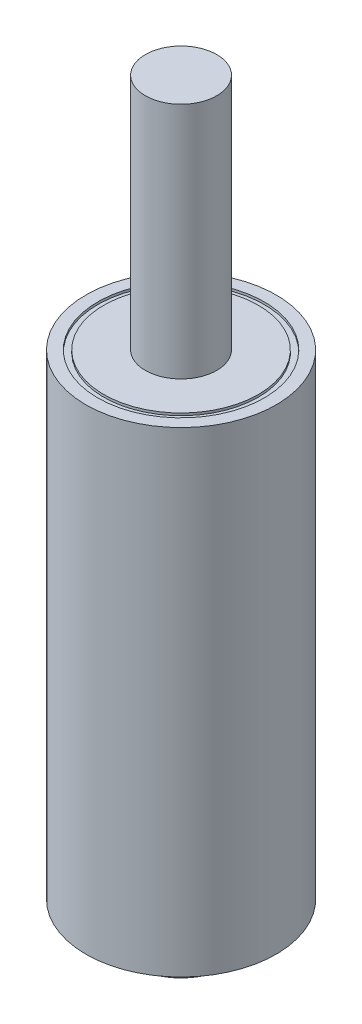
from build123d import *

# Parameters (mm, degrees)
SKETCH1_R               = 4
BOSS_EXTRUDE1_DEPTH     = 20
SKETCH2_R               = 3.5
SKETCH2_R_2             = 3.25
CUT_EXTRUDE_THIN1_DEPTH = 0.1
SKETCH3_R               = 2
BOSS_EXTRUDE2_DEPTH     = 0.2
FILLET1_R               = 0.1
SKETCH4_R               = 2
BOSS_EXTRUDE3_DEPTH     = 1
FILLET2_R               = 0.1
SKETCH5_R               = 1.25
BOSS_EXTRUDE4_DEPTH     = 0.5
CHAMFER1_SIZE           = 0.2
BOSS_EXTRUDE5_DEPTH     = 0.25
SKETCH7_R               = 1.5
BOSS_EXTRUDE6_DEPTH     = 10
SKETCH8_R               = 3.5
SKETCH8_R_2             = 3.25
CUT_EXTRUDE_THIN2_DEPTH = 0.1


with BuildPart() as part:
    # Sketch1 → Boss-Extrude1 (new body)
    with BuildSketch(Plane(origin=(0, 0, 0), x_dir=(1, 0, 0), z_dir=(0, 1, 0))):
        Circle(SKETCH1_R)
    extrude(amount=BOSS_EXTRUDE1_DEPTH)

    # Sketch2 → Cut-Extrude-Thin1 (cut)
    with BuildSketch(Plane.XZ):
        Circle(SKETCH2_R)
        Circle(SKETCH2_R_2, mode=Mode.SUBTRACT)
    extrude(amount=-CUT_EXTRUDE_THIN1_DEPTH, mode=Mode.SUBTRACT)

    # Sketch3 → Boss-Extrude2 (add)
    with BuildSketch(Plane.XZ):
        Circle(SKETCH3_R)
    extrude(amount=BOSS_EXTRUDE2_DEPTH)

    # Fillet1
    fillet1_edges = [part.edges().sort_by_distance(p)[0] for p in [
        (-2, -0.2, 0),
    ]]
    fillet(fillet1_edges, radius=FILLET1_R)

    # Sketch4 → Boss-Extrude3 (add)
    with BuildSketch(Plane.XZ.offset(0.2)):
        Circle(SKETCH4_R)
    extrude(amount=BOSS_EXTRUDE3_DEPTH)

    # Fillet2
    fillet2_edges = [part.edges().sort_by_distance(p)[0] for p in [
        (-2, -1.2, 0),
    ]]
    fillet(fillet2_edges, radius=FILLET2_R)

    # Sketch5 → Boss-Extrude4 (add)
    with BuildSketch(Plane.XZ.offset(1.2)):
        Circle(SKETCH5_R)
    extrude(amount=BOSS_EXTRUDE4_DEPTH)

    # Chamfer1
    chamfer1_edges = [part.edges().sort_by_distance(p)[0] for p in [
        (-1.25, -1.7, 0),
    ]]
    chamfer(chamfer1_edges, length=CHAMFER1_SIZE)

    # Sketch6 → Boss-Extrude5 (add)
    with BuildSketch(Plane.XZ.offset(1.2)):
        with BuildLine():
            Line((0, -1.25), (0, -2))
            ThreePointArc((0, -2), (-1.414213562, 1.414213562), (2, 0))
            Line((2, 0), (1.25, 0))
            ThreePointArc((1.25, 0), (-0.883883476, 0.883883476), (0, -1.25))
        make_face()
    extrude(amount=BOSS_EXTRUDE5_DEPTH)

    # Sketch7 → Boss-Extrude6 (add)
    with BuildSketch(Plane(origin=(0, 20, 0), x_dir=(1, 0, 0), z_dir=(0, 1, 0))):
        Circle(SKETCH7_R)
    extrude(amount=BOSS_EXTRUDE6_DEPTH)

    # Sketch8 → Cut-Extrude-Thin2 (cut)
    with BuildSketch(Plane(origin=(0, 20, 0), x_dir=(1, 0, 0), z_dir=(0, 1, 0))):
        Circle(SKETCH8_R)
        Circle(SKETCH8_R_2, mode=Mode.SUBTRACT)
    extrude(amount=-CUT_EXTRUDE_THIN2_DEPTH, mode=Mode.SUBTRACT)


solid = part.part
